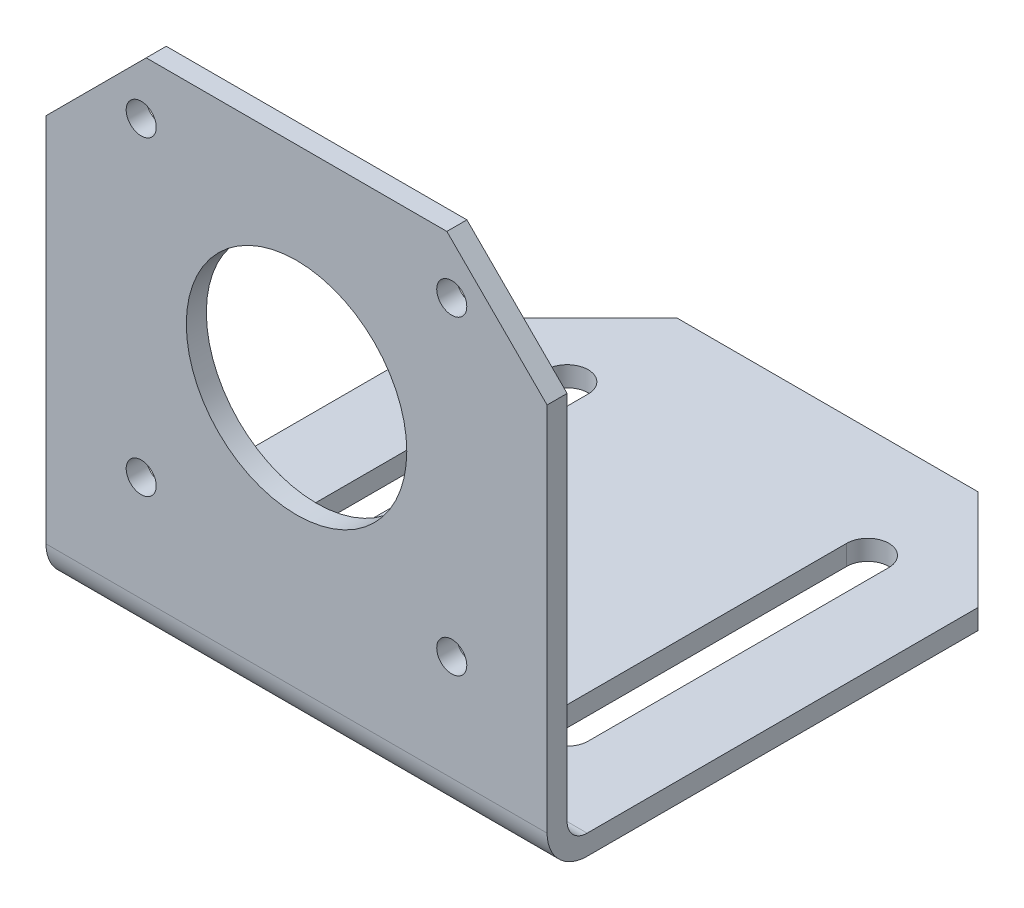
from build123d import *

# Parameters (mm, degrees)
BOSS_EXTRUDE1_DEPTH = 50
SKETCH2_R           = 11
SKETCH2_R_2         = 1.5
CUT_EXTRUDE1_DEPTH  = 2
CUT_EXTRUDE2_DEPTH  = 2
CUT_EXTRUDE3_DEPTH  = 2
CUT_EXTRUDE4_DEPTH  = 2


with BuildPart() as part:
    # Sketch1 → Boss-Extrude1 (new body)
    with BuildSketch(Plane(origin=(0, 0, 0), x_dir=(0, 0, -1), z_dir=(1, 0, 0))):
        with BuildLine():
            Line((4, 0), (53, 0))
            Line((53, 0), (53, 2))
            Line((53, 2), (4, 2))
            ThreePointArc((4, 2), (2.585786438, 2.585786438), (2, 4))
            Line((2, 4), (2, 51))
            Line((2, 51), (0, 51))
            Line((0, 51), (0, 4))
            ThreePointArc((0, 4), (1.171572875, 1.171572875), (4, 0))
        make_face()
    extrude(amount=BOSS_EXTRUDE1_DEPTH)

    # Sketch2 → Cut-Extrude1 (cut)
    with BuildSketch(Plane(origin=(0, 0, -2), x_dir=(-1, 0, 0), z_dir=(0, 0, -1))):
        with Locations((-25, 30)):
            Circle(SKETCH2_R)
        with Locations((-9.5, 45.5)):
            Circle(SKETCH2_R_2)
        with Locations((-40.488, 45.5)):
            Circle(SKETCH2_R_2)
        with Locations((-40.488, 14.5)):
            Circle(SKETCH2_R_2)
        with Locations((-9.5, 14.5)):
            Circle(SKETCH2_R_2)
    extrude(amount=-CUT_EXTRUDE1_DEPTH, mode=Mode.SUBTRACT)

    # Sketch3 → Cut-Extrude2 (cut)
    with BuildSketch(Plane(origin=(0, 2, 0), x_dir=(1, 0, 0), z_dir=(0, 1, 0))):
        with BuildLine():
            Line((42.1, 42), (42.1, 12))
            ThreePointArc((42.1, 12), (40, 9.9), (37.9, 12))
            Line((37.9, 12), (37.9, 42))
            ThreePointArc((37.9, 42), (40, 44.1), (42.1, 42))
        make_face()
        with BuildLine():
            Line((7.9, 42), (7.9, 12))
            ThreePointArc((7.9, 12), (10, 9.9), (12.1, 12))
            Line((12.1, 12), (12.1, 42))
            ThreePointArc((12.1, 42), (10, 44.1), (7.9, 42))
        make_face()
    extrude(amount=-CUT_EXTRUDE2_DEPTH, mode=Mode.SUBTRACT)

    # Sketch4 → Cut-Extrude3 (cut)
    with BuildSketch(Plane(origin=(0, 2, 0), x_dir=(1, 0, 0), z_dir=(0, 1, 0))):
        Polygon((0, 53), (0, 43), (10, 53), align=None)
        Polygon((50, 53), (40, 53), (50, 43), align=None)
    extrude(amount=-CUT_EXTRUDE3_DEPTH, mode=Mode.SUBTRACT)

    # Sketch5 → Cut-Extrude4 (cut)
    with BuildSketch(Plane(origin=(0, 0, -2), x_dir=(-1, 0, 0), z_dir=(0, 0, -1))):
        Polygon((-50, 41), (-40, 51), (-50, 51), align=None)
        Polygon((-10, 51), (0, 41), (0, 51), align=None)
    extrude(amount=-CUT_EXTRUDE4_DEPTH, mode=Mode.SUBTRACT)


solid = part.part
